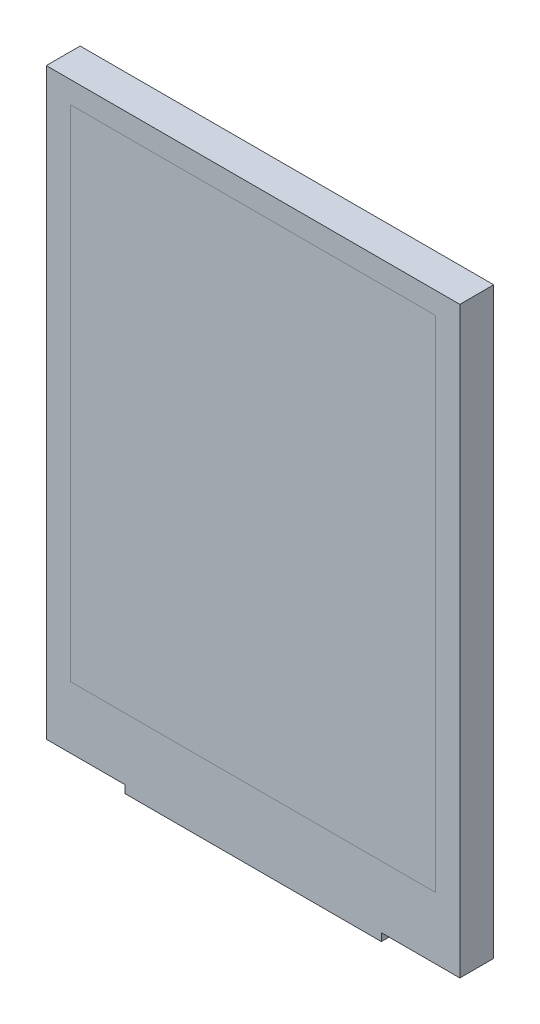
from build123d import *

# Parameters (mm, degrees)
SKETCH1_W           = 42.72
SKETCH1_H           = 60.26
SKETCH1_W_2         = 37.72
SKETCH1_H_2         = 51.61
SKETCH1_W_3         = 26.5
SKETCH1_H_3         = 0.8
BOSS_EXTRUDE1_DEPTH = 3.5
SKETCH1_3_W         = 37.72
SKETCH1_3_H         = 51.61
BOSS_EXTRUDE2_DEPTH = 3.5


with BuildPart() as part:
    # Sketch1 → Boss-Extrude1 (new body)
    with BuildSketch(Plane.XY):
        with Locations((0, -2.075)):
            Rectangle(SKETCH1_W, SKETCH1_H)
        Rectangle(SKETCH1_W_2, SKETCH1_H_2, mode=Mode.SUBTRACT)
        with Locations((0, -32.605)):
            Rectangle(SKETCH1_W_3, SKETCH1_H_3)
    extrude(amount=BOSS_EXTRUDE1_DEPTH)


with BuildPart() as body_2:
    # Sketch1_3 → Boss-Extrude2 (new body)
    with BuildSketch(Plane.XY):
        Rectangle(SKETCH1_3_W, SKETCH1_3_H)
    extrude(amount=BOSS_EXTRUDE2_DEPTH)


solid = Compound([part.part, body_2.part])
